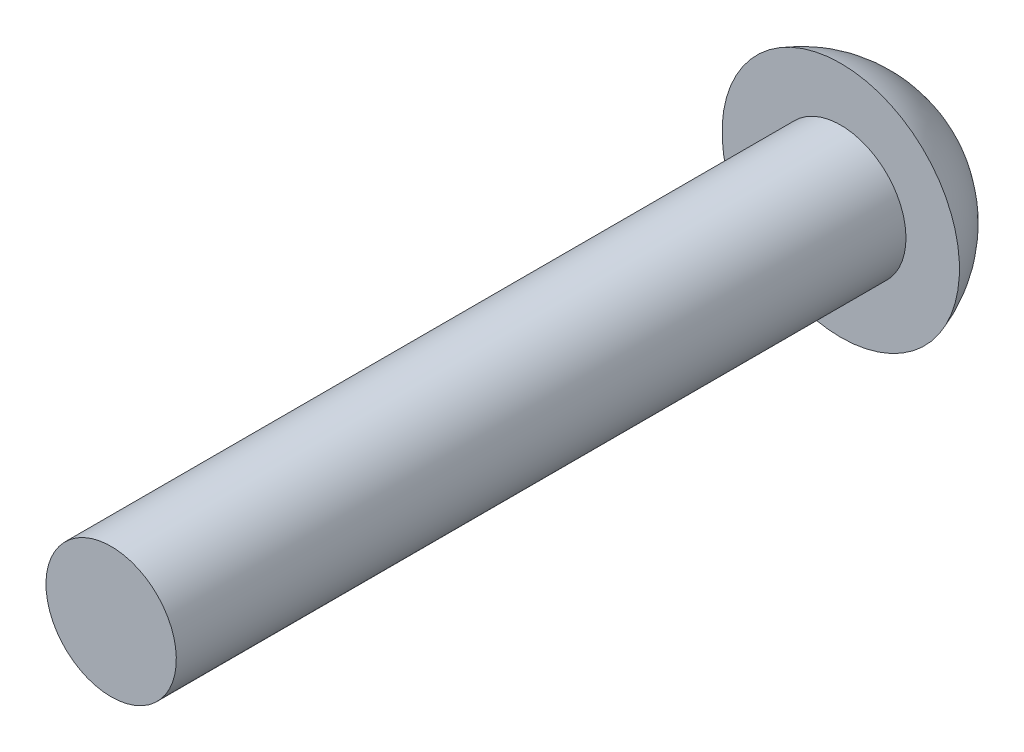
from build123d import *


with BuildPart() as part:
    # Sketch2 → Revolve1 (revolve)
    with BuildSketch(Plane(origin=(0, 0, 0), x_dir=(0, 0, -1), z_dir=(1, 0, 0))):
        with BuildLine():
            Line((0, 0), (0, 1.7018))
            Line((0, 1.7018), (19.05, 1.7018))
            Line((19.05, 1.7018), (19.05, 3.0988))
            ThreePointArc((19.05, 3.0988), (20.668092498, 1.910410982), (21.2852, 0))
            Line((21.2852, 0), (0, 0))
        make_face()
    revolve(axis=Axis((0, 0, 0), (0, 0, -1)))


solid = part.part
